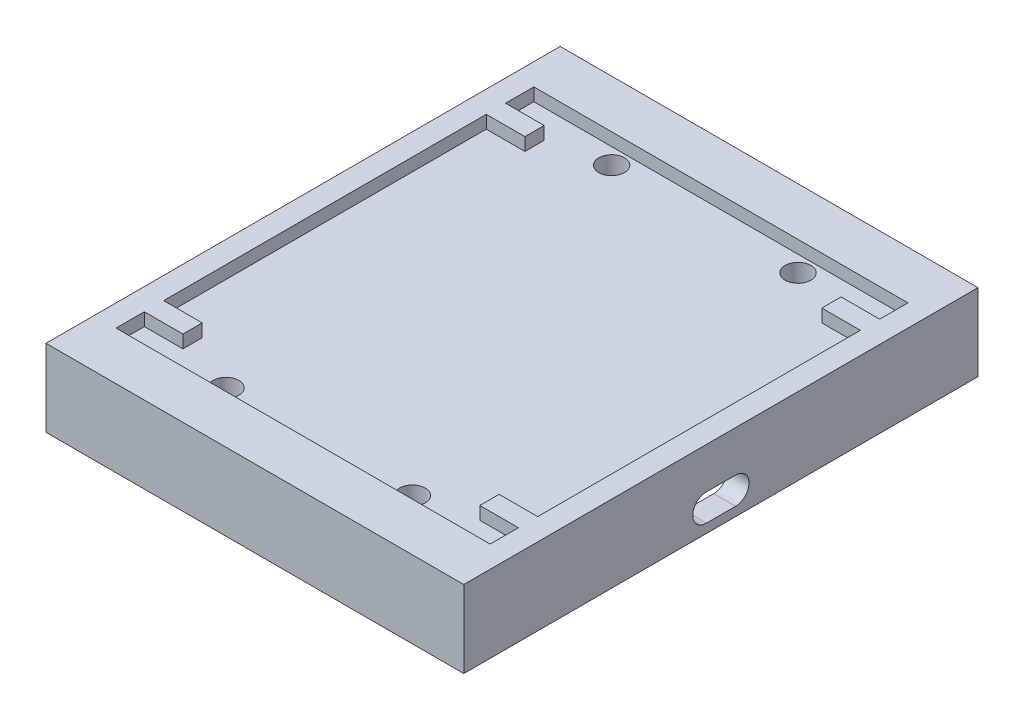
from build123d import *

# Parameters (mm, degrees)
SKETCH1_W           = 65
SKETCH1_H           = 80
BOSS_EXTRUDE1_DEPTH = 12
SKETCH3_W           = 58.2
SKETCH3_H           = 65
CUT_EXTRUDE4_DEPTH  = 2
SKETCH6_R           = 2
CUT_EXTRUDE5_DEPTH  = 10
SKETCH7_W           = 58.2
SKETCH7_H           = 65
CUT_EXTRUDE6_DEPTH  = 7
CUT_EXTRUDE8_DEPTH  = 6
SKETCH11_W          = 3
SKETCH11_H          = 2
BOSS_EXTRUDE3_DEPTH = 6
SKETCH13_W          = 3
SKETCH13_H          = 2
BOSS_EXTRUDE4_DEPTH = 6


with BuildPart() as part:
    # Sketch1 → Boss-Extrude1 (new body)
    with BuildSketch(Plane(origin=(0, 0, 0), x_dir=(1, 0, 0), z_dir=(0, 1, 0))):
        Rectangle(SKETCH1_W, SKETCH1_H)
    extrude(amount=BOSS_EXTRUDE1_DEPTH)

    # Sketch3 → Cut-Extrude4 (cut)
    with BuildSketch(Plane(origin=(0, 12, 0), x_dir=(1, 0, 0), z_dir=(0, 1, 0))):
        Rectangle(SKETCH3_W, SKETCH3_H)
    extrude(amount=-CUT_EXTRUDE4_DEPTH, mode=Mode.SUBTRACT)

    # Sketch6 → Cut-Extrude5 (cut)
    with BuildSketch(Plane(origin=(0, 10, 0), x_dir=(1, 0, 0), z_dir=(0, 1, 0))):
        with Locations(Location((14.5, 30, 0), (0, 0, 270))):  # turned: the seam where the file's is
            Circle(SKETCH6_R)
        with Locations(Location((-14.5, 30, 0), (0, 0, 90))):  # turned: the seam where the file's is
            Circle(SKETCH6_R)
        with Locations(Location((-14.5, -30, 0), (0, 0, 270))):  # turned: the seam where the file's is
            Circle(SKETCH6_R)
        with Locations(Location((14.5, -30, 0), (0, 0, 90))):  # turned: the seam where the file's is
            Circle(SKETCH6_R)
    extrude(amount=-CUT_EXTRUDE5_DEPTH, mode=Mode.SUBTRACT)

    # Sketch7 → Cut-Extrude6 (cut)
    with BuildSketch(Plane(origin=(0, 0, 0), x_dir=(1, 0, 0), z_dir=(0, 1, 0))):
        Rectangle(SKETCH7_W, SKETCH7_H)
    extrude(amount=CUT_EXTRUDE6_DEPTH, mode=Mode.SUBTRACT)

    # Sketch10 → Cut-Extrude8 (cut)
    with BuildSketch(Plane.ZY.offset(-29.1)):
        with BuildLine():
            Line((-2.277690302, 5.601430768), (2.277690302, 5.601430768))
            ThreePointArc((2.277690302, 5.601430768), (4.379121071, 3.5), (2.277690302, 1.398569232))
            Line((2.277690302, 1.398569232), (-2.277690302, 1.398569232))
            ThreePointArc((-2.277690302, 1.398569232), (-4.379121071, 3.5), (-2.277690302, 5.601430768))
        make_face()
    extrude(amount=-CUT_EXTRUDE8_DEPTH, mode=Mode.SUBTRACT)

    # Sketch11 → Boss-Extrude3 (add)
    with BuildSketch(Plane.ZY.offset(-29.1)):
        with Locations((-26.6, 11)):
            Rectangle(SKETCH11_W, SKETCH11_H)
        with Locations((26.6, 11)):
            Rectangle(SKETCH11_W, SKETCH11_H)
    extrude(amount=BOSS_EXTRUDE3_DEPTH)

    # Sketch13 → Boss-Extrude4 (add)
    with BuildSketch(Plane(origin=(-29.1, 0, 0), x_dir=(0, 0, -1), z_dir=(1, 0, 0))):
        with Locations((26.6, 11)):
            Rectangle(SKETCH13_W, SKETCH13_H)
        with Locations((-26.6, 11)):
            Rectangle(SKETCH13_W, SKETCH13_H)
    extrude(amount=BOSS_EXTRUDE4_DEPTH)


solid = part.part
